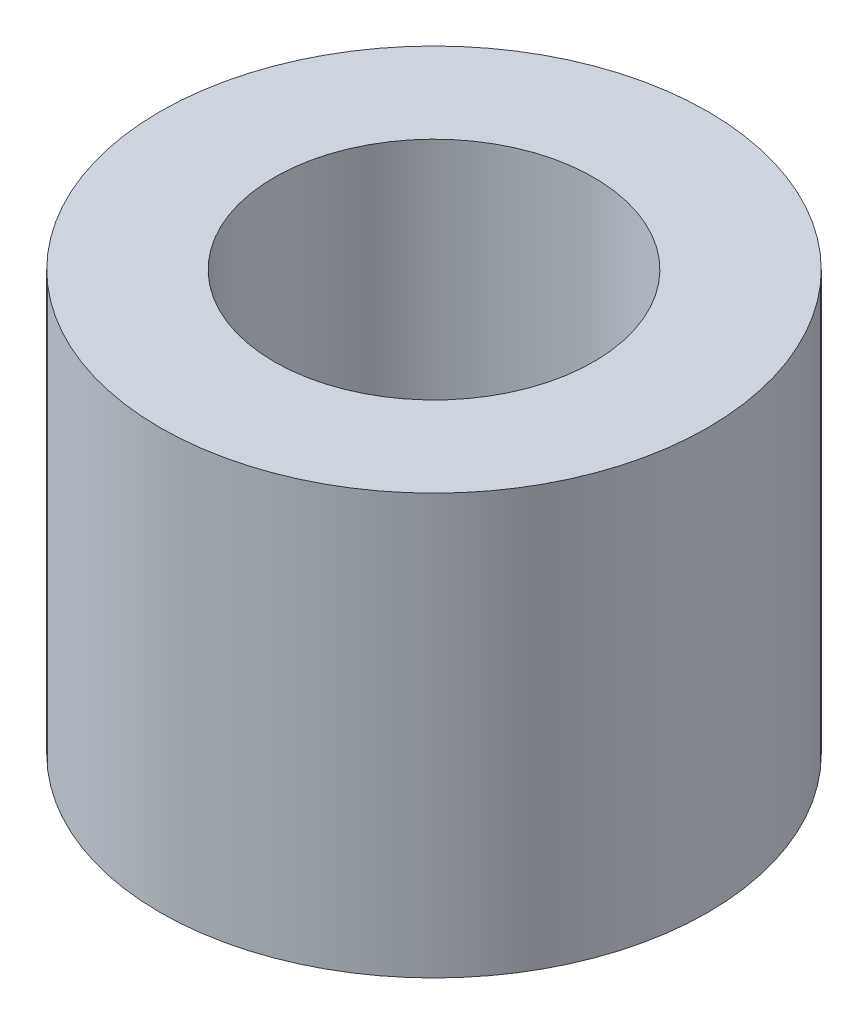
from build123d import *

# Parameters (mm, degrees)
SKETCH1_R           = 3
SKETCH1_R_2         = 1.75
BOSS_EXTRUDE1_DEPTH = 4.6


with BuildPart() as part:
    # Sketch1 → Boss-Extrude1 (new body)
    with BuildSketch(Plane(origin=(0, 0, 0), x_dir=(1, 0, 0), z_dir=(0, 1, 0))):
        Circle(SKETCH1_R)
        Circle(SKETCH1_R_2, mode=Mode.SUBTRACT)
    extrude(amount=BOSS_EXTRUDE1_DEPTH)


solid = part.part
